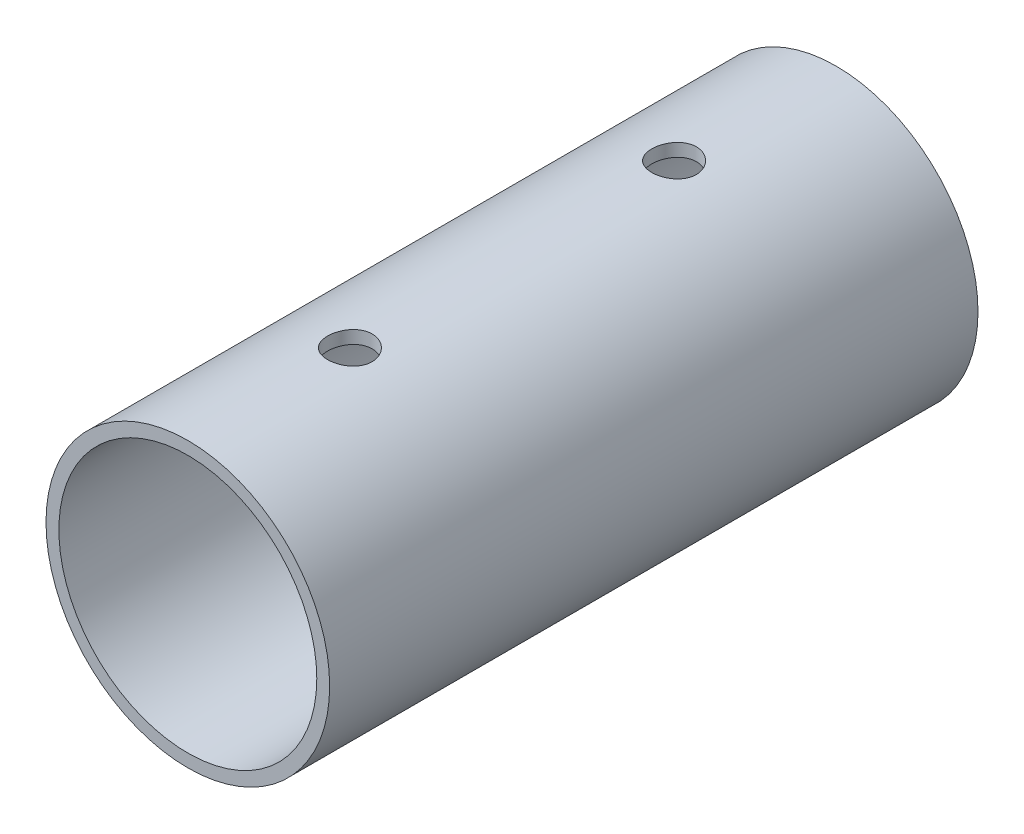
from build123d import *

# Parameters (mm, degrees)
SKETCH1_R                                  = 17.5
SKETCH1_R_2                                = 15.9125
BOSS_EXTRUDE1_DEPTH                        = 40
SKETCH5_W                                  = 2.75
SKETCH5_H                                  = 17.5
MIRROR1_AT_THE_SECOND_PLANE_COPY_1_SKETC_W = 2.75
MIRROR1_AT_THE_SECOND_PLANE_COPY_1_SKETC_H = 17.5


with BuildPart() as part:
    # Sketch1 → Boss-Extrude1 (new body, symmetric)
    with BuildSketch(Plane.XY):
        Circle(SKETCH1_R)
        Circle(SKETCH1_R_2, mode=Mode.SUBTRACT)
    extrude(amount=BOSS_EXTRUDE1_DEPTH, both=True)

    # Sketch5 → M5 Clearance Hole1 (revolve, cut)
    with BuildSketch(Plane(origin=(0, 0, -20), x_dir=(0, 0, -1), z_dir=(1, 0, 0))):
        with Locations((1.375, 8.75)):
            Rectangle(SKETCH5_W, SKETCH5_H)
    m5_clearance_hole1 = revolve(axis=Axis((0, -6.35, -20), (0, 1, 0)), mode=Mode.SUBTRACT)

    # Mirror1: M5 Clearance Hole1 across plane
    add(m5_clearance_hole1.mirror(Plane.XY), mode=Mode.SUBTRACT)

    # Mirror1 at the second plane: M5 Clearance Hole1 across plane
    add(m5_clearance_hole1.mirror(Plane.ZX), mode=Mode.SUBTRACT)

    # Mirror1 at the second plane copy 1 sketc → Mirror1 at the second plane copy 1 (revolve, cut)
    with BuildSketch(Plane(origin=(0, 0, 20), x_dir=(0, 0, 1), z_dir=(1, 0, 0))):
        with Locations((1.375, 8.75)):
            Rectangle(MIRROR1_AT_THE_SECOND_PLANE_COPY_1_SKETC_W, MIRROR1_AT_THE_SECOND_PLANE_COPY_1_SKETC_H)
    revolve(axis=Axis((0, 6.35, 20), (0, -1, 0)), mode=Mode.SUBTRACT)


solid = part.part
